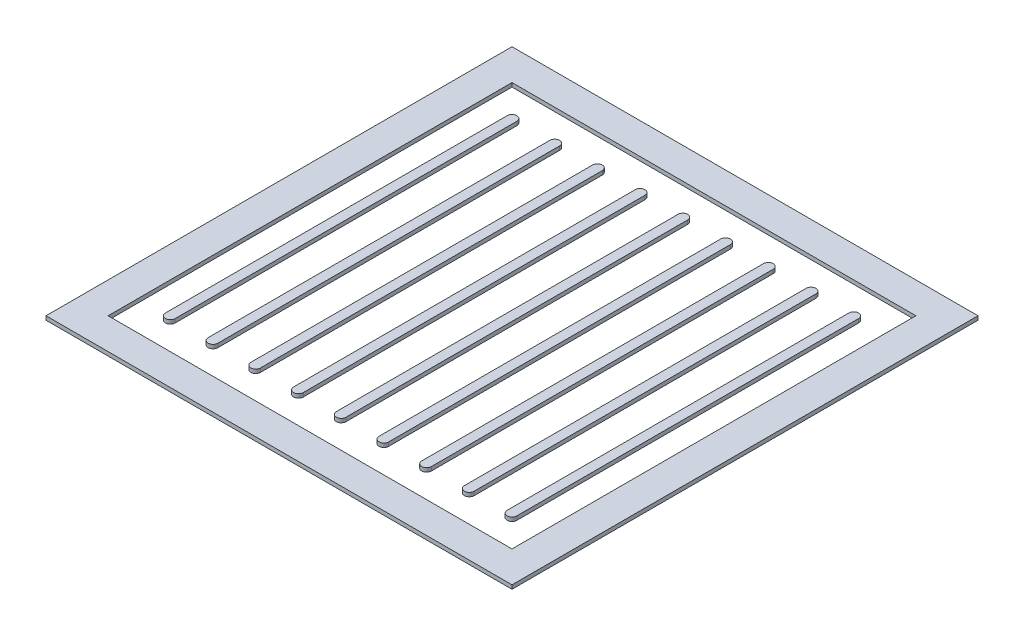
from build123d import *

# Parameters (mm, degrees)
SKETCH1_W              = 381
SKETCH1_H              = 381
SKETCH1_W_2            = 330.2
SKETCH1_H_2            = 330.2
BOSS_EXTRUDE1_DEPTH    = 3.175
BOSS_EXTRUDE1_2_DEPTH  = 3.175
BOSS_EXTRUDE1_3_DEPTH  = 3.175
BOSS_EXTRUDE1_4_DEPTH  = 3.175
BOSS_EXTRUDE1_5_DEPTH  = 3.175
BOSS_EXTRUDE1_6_DEPTH  = 3.175
BOSS_EXTRUDE1_7_DEPTH  = 3.175
BOSS_EXTRUDE1_8_DEPTH  = 3.175
BOSS_EXTRUDE1_9_DEPTH  = 3.175
BOSS_EXTRUDE1_10_DEPTH = 3.175


with BuildPart() as part:
    # Sketch1 → Boss-Extrude1 (new body)
    with BuildSketch(Plane(origin=(0, 0, 0), x_dir=(1, 0, 0), z_dir=(0, 1, 0))):
        Rectangle(SKETCH1_W, SKETCH1_H)
        Rectangle(SKETCH1_W_2, SKETCH1_H_2, mode=Mode.SUBTRACT)
    extrude(amount=BOSS_EXTRUDE1_DEPTH)


with BuildPart() as body_2:
    # Sketch1 → Boss-Extrude1 2 (new body)
    with BuildSketch(Plane(origin=(0, 0, 0), x_dir=(1, 0, 0), z_dir=(0, 1, 0))):
        with BuildLine():
            Line((100.80625, 139.7), (100.80625, -139.7))
            ThreePointArc((100.80625, -139.7), (104.775, -143.66875), (108.74375, -139.7))
            Line((108.74375, -139.7), (108.74375, 139.7))
            ThreePointArc((108.74375, 139.7), (104.775, 143.66875), (100.80625, 139.7))
        make_face()
    extrude(amount=BOSS_EXTRUDE1_2_DEPTH)


with BuildPart() as body_3:
    # Sketch1 → Boss-Extrude1 3 (new body)
    with BuildSketch(Plane(origin=(0, 0, 0), x_dir=(1, 0, 0), z_dir=(0, 1, 0))):
        with BuildLine():
            Line((135.73125, 139.7), (135.73125, -139.7))
            ThreePointArc((135.73125, -139.7), (139.7, -143.66875), (143.66875, -139.7))
            Line((143.66875, -139.7), (143.66875, 139.7))
            ThreePointArc((143.66875, 139.7), (139.7, 143.66875), (135.73125, 139.7))
        make_face()
    extrude(amount=BOSS_EXTRUDE1_3_DEPTH)


with BuildPart() as body_4:
    # Sketch1 → Boss-Extrude1 4 (new body)
    with BuildSketch(Plane(origin=(0, 0, 0), x_dir=(1, 0, 0), z_dir=(0, 1, 0))):
        with BuildLine():
            Line((65.88125, 139.7), (65.88125, -139.7))
            ThreePointArc((65.88125, -139.7), (69.85, -143.66875), (73.81875, -139.7))
            Line((73.81875, -139.7), (73.81875, 139.7))
            ThreePointArc((73.81875, 139.7), (69.85, 143.66875), (65.88125, 139.7))
        make_face()
    extrude(amount=BOSS_EXTRUDE1_4_DEPTH)


with BuildPart() as body_5:
    # Sketch1 → Boss-Extrude1 5 (new body)
    with BuildSketch(Plane(origin=(0, 0, 0), x_dir=(1, 0, 0), z_dir=(0, 1, 0))):
        with BuildLine():
            Line((30.95625, 139.7), (30.95625, -139.7))
            ThreePointArc((30.95625, -139.7), (34.925, -143.66875), (38.89375, -139.7))
            Line((38.89375, -139.7), (38.89375, 139.7))
            ThreePointArc((38.89375, 139.7), (34.925, 143.66875), (30.95625, 139.7))
        make_face()
    extrude(amount=BOSS_EXTRUDE1_5_DEPTH)


with BuildPart() as body_6:
    # Sketch1 → Boss-Extrude1 6 (new body)
    with BuildSketch(Plane(origin=(0, 0, 0), x_dir=(1, 0, 0), z_dir=(0, 1, 0))):
        with BuildLine():
            Line((-3.96875, 139.7), (-3.96875, -139.7))
            ThreePointArc((-3.96875, -139.7), (0, -143.66875), (3.96875, -139.7))
            Line((3.96875, -139.7), (3.96875, 139.7))
            ThreePointArc((3.96875, 139.7), (0, 143.66875), (-3.96875, 139.7))
        make_face()
    extrude(amount=BOSS_EXTRUDE1_6_DEPTH)


with BuildPart() as body_7:
    # Sketch1 → Boss-Extrude1 7 (new body)
    with BuildSketch(Plane(origin=(0, 0, 0), x_dir=(1, 0, 0), z_dir=(0, 1, 0))):
        with BuildLine():
            Line((-73.81875, 139.7), (-73.81875, -139.7))
            ThreePointArc((-73.81875, -139.7), (-69.85, -143.66875), (-65.88125, -139.7))
            Line((-65.88125, -139.7), (-65.88125, 139.7))
            ThreePointArc((-65.88125, 139.7), (-69.85, 143.66875), (-73.81875, 139.7))
        make_face()
    extrude(amount=BOSS_EXTRUDE1_7_DEPTH)


with BuildPart() as body_8:
    # Sketch1 → Boss-Extrude1 8 (new body)
    with BuildSketch(Plane(origin=(0, 0, 0), x_dir=(1, 0, 0), z_dir=(0, 1, 0))):
        with BuildLine():
            Line((-38.89375, 139.7), (-38.89375, -139.7))
            ThreePointArc((-38.89375, -139.7), (-34.925, -143.66875), (-30.95625, -139.7))
            Line((-30.95625, -139.7), (-30.95625, 139.7))
            ThreePointArc((-30.95625, 139.7), (-34.925, 143.66875), (-38.89375, 139.7))
        make_face()
    extrude(amount=BOSS_EXTRUDE1_8_DEPTH)


with BuildPart() as body_9:
    # Sketch1 → Boss-Extrude1 9 (new body)
    with BuildSketch(Plane(origin=(0, 0, 0), x_dir=(1, 0, 0), z_dir=(0, 1, 0))):
        with BuildLine():
            Line((-108.74375, 139.7), (-108.74375, -139.7))
            ThreePointArc((-108.74375, -139.7), (-104.775, -143.66875), (-100.80625, -139.7))
            Line((-100.80625, -139.7), (-100.80625, 139.7))
            ThreePointArc((-100.80625, 139.7), (-104.775, 143.66875), (-108.74375, 139.7))
        make_face()
    extrude(amount=BOSS_EXTRUDE1_9_DEPTH)


with BuildPart() as body_10:
    # Sketch1 → Boss-Extrude1 10 (new body)
    with BuildSketch(Plane(origin=(0, 0, 0), x_dir=(1, 0, 0), z_dir=(0, 1, 0))):
        with BuildLine():
            Line((-143.66875, 139.7), (-143.66875, -139.7))
            ThreePointArc((-143.66875, -139.7), (-139.7, -143.66875), (-135.73125, -139.7))
            Line((-135.73125, -139.7), (-135.73125, 139.7))
            ThreePointArc((-135.73125, 139.7), (-139.7, 143.66875), (-143.66875, 139.7))
        make_face()
    extrude(amount=BOSS_EXTRUDE1_10_DEPTH)


solid = Compound([part.part, body_2.part, body_3.part, body_4.part, body_5.part, body_6.part, body_7.part, body_8.part, body_9.part, body_10.part])
